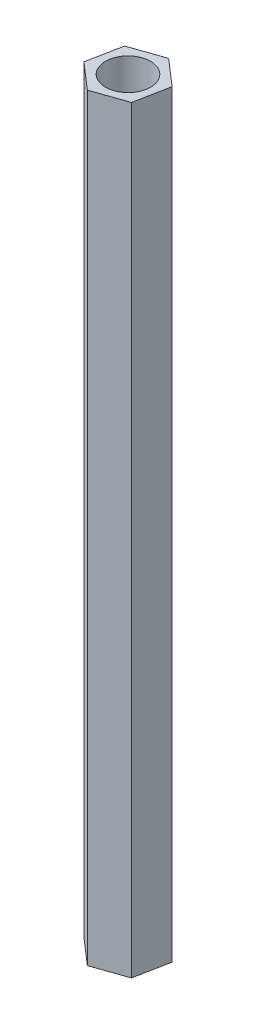
from build123d import *

# Parameters (mm, degrees)
BOSS_EXTRUDE1_DEPTH = 50.5
SKETCH2_R           = 1.5
CUT_EXTRUDE1_DEPTH  = 51.5


with BuildPart() as part:
    # Sketch1 → Boss-Extrude1 (new body)
    with BuildSketch(Plane(origin=(0, 0, 0), x_dir=(1, 0, 0), z_dir=(0, 1, 0))):
        Polygon((1.744925055, -1.512801998), (2.182587489, 0.754748427), (0.437662433, 2.267550425), (-1.744925055, 1.512801998), (-2.182587489, -0.754748427), (-0.437662433, -2.267550425), align=None)
    extrude(amount=BOSS_EXTRUDE1_DEPTH)

    # Sketch2 → Cut-Extrude1 (cut, through all)
    with BuildSketch(Plane(origin=(0, 50.5, 0), x_dir=(1, 0, 0), z_dir=(0, 1, 0))):
        Circle(SKETCH2_R)
    extrude(amount=-CUT_EXTRUDE1_DEPTH, mode=Mode.SUBTRACT)


solid = part.part
